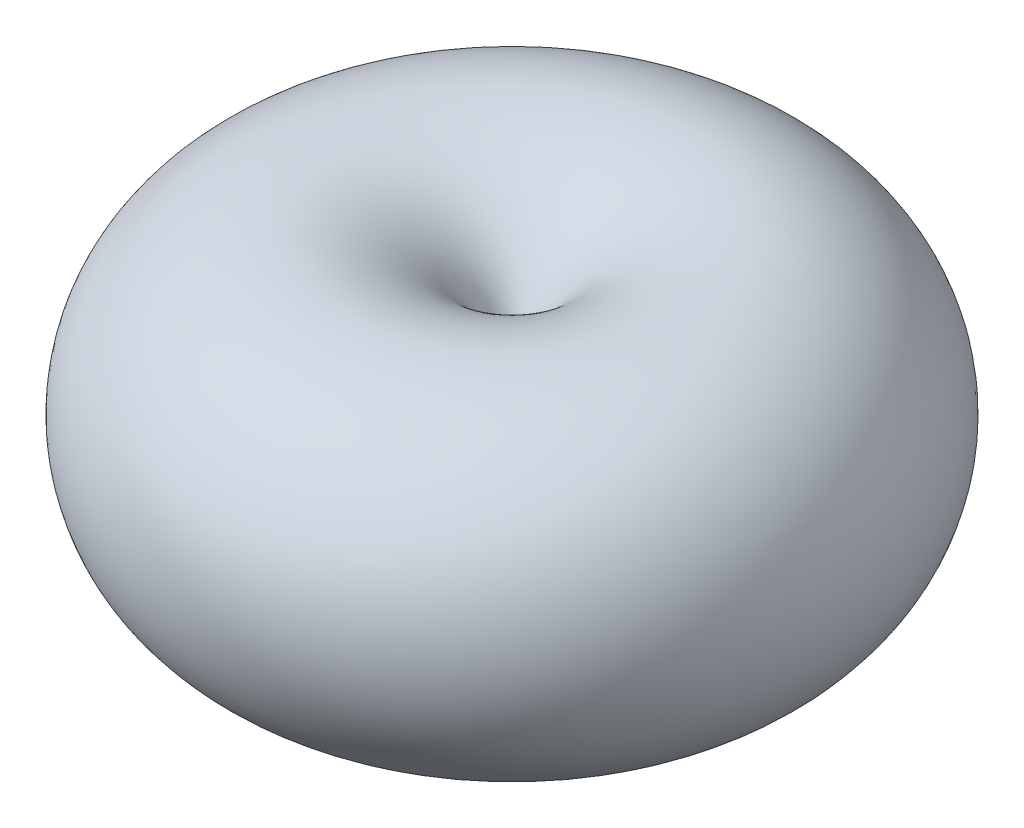
from build123d import *


with BuildPart() as part:
    # Sketch1 one side → Revolve7 (revolve)
    with BuildSketch(Plane.XY):
        with BuildLine():
            ThreePointArc((0, -1.541195548), (9.641170314, -10.050151051), (18.543101552, -0.770597774))
            ThreePointArc((18.543101552, -0.770597774), (9.641170314, 8.508955503), (0, 0))
            Line((0, 0), (0, -1.541195548))
        make_face()
    revolve(axis=Axis((0, 20, 0), (0, -1, 0)))


solid = part.part
